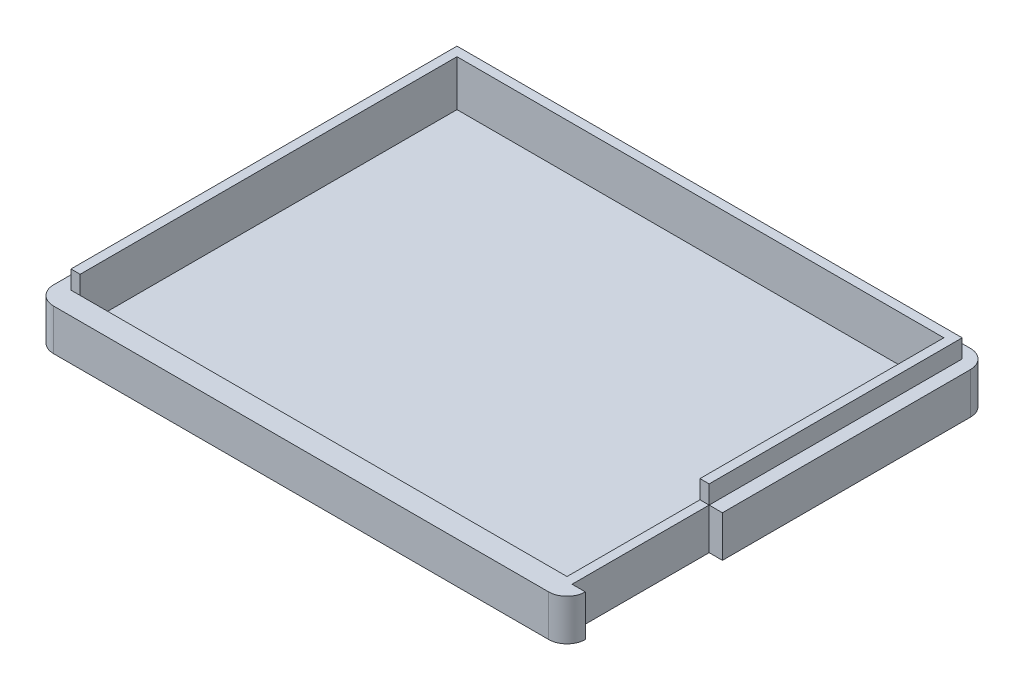
from build123d import *

# Parameters (mm, degrees)
SKETCH1_W           = 58
SKETCH1_H           = 46
BOSS_EXTRUDE1_DEPTH = 4.5
SKETCH2_W           = 55.1
SKETCH2_H           = 43.1
SKETCH2_W_2         = 53.1
SKETCH2_H_2         = 41.1
BOSS_EXTRUDE2_DEPTH = 2
SKETCH3_W           = 53.1
SKETCH3_H           = 41.1
CUT_EXTRUDE1_DEPTH  = 3
SKETCH4_W           = 1
SKETCH4_H           = 15.5
CUT_EXTRUDE2_DEPTH  = 2
CUT_EXTRUDE4_START  = 5
SKETCH5_W           = 54.1
SKETCH5_H           = 1
CUT_EXTRUDE4_DEPTH  = 2
FILLET1_R           = 2
SKETCH6_W           = 1.45
SKETCH6_H           = 14.95
CUT_EXTRUDE5_DEPTH  = 5.5


with BuildPart() as part:
    # Sketch1 → Boss-Extrude1 (new body)
    with BuildSketch(Plane(origin=(0, 0, 0), x_dir=(1, 0, 0), z_dir=(0, 1, 0))):
        with Locations((2.929896907, -5.540206186)):
            Rectangle(SKETCH1_W, SKETCH1_H)
    extrude(amount=BOSS_EXTRUDE1_DEPTH)

    # Sketch2 → Boss-Extrude2 (add)
    with BuildSketch(Plane(origin=(0, 4.5, 0), x_dir=(1, 0, 0), z_dir=(0, 1, 0))):
        with Locations((2.929896907, -5.540206186)):
            Rectangle(SKETCH2_W, SKETCH2_H)
        with Locations((2.929896907, -5.540206186)):
            Rectangle(SKETCH2_W_2, SKETCH2_H_2, mode=Mode.SUBTRACT)
    extrude(amount=BOSS_EXTRUDE2_DEPTH)

    # Sketch3 → Cut-Extrude1 (cut)
    with BuildSketch(Plane(origin=(0, 4.5, 0), x_dir=(1, 0, 0), z_dir=(0, 1, 0))):
        with Locations((2.929896907, -5.540206186)):
            Rectangle(SKETCH3_W, SKETCH3_H)
    extrude(amount=-CUT_EXTRUDE1_DEPTH, mode=Mode.SUBTRACT)

    # Sketch4 → Cut-Extrude2 (cut)
    with BuildSketch(Plane(origin=(0, 6.5, 0), x_dir=(1, 0, 0), z_dir=(0, 1, 0))):
        with Locations((29.979896907, -19.340206186)):
            Rectangle(SKETCH4_W, SKETCH4_H)
    extrude(amount=-CUT_EXTRUDE2_DEPTH, mode=Mode.SUBTRACT)

    # Sketch5 → Cut-Extrude4 (cut)
    with BuildSketch(Plane(origin=(0, 1.5, 0), x_dir=(1, 0, 0), z_dir=(0, 1, 0)).offset(CUT_EXTRUDE4_START)):
        with Locations((2.429896907, -26.590206186)):
            Rectangle(SKETCH5_W, SKETCH5_H)
    extrude(amount=-CUT_EXTRUDE4_DEPTH, mode=Mode.SUBTRACT)

    # Fillet1
    fillet1_edges = [part.edges().sort_by_distance(p)[0] for p in [
        (-26.070103093, 2.25, -17.459793814),
        (31.929896907, 2.25, -17.459793814),
        (31.929896907, 2.25, 28.540206186),
        (-26.070103093, 2.25, 28.540206186),
    ]]
    fillet(fillet1_edges, radius=FILLET1_R)

    # Sketch6 → Cut-Extrude5 (cut, through all)
    with BuildSketch(Plane(origin=(0, 4.5, 0), x_dir=(1, 0, 0), z_dir=(0, 1, 0))):
        with Locations((31.204896907, -19.065206186)):
            Rectangle(SKETCH6_W, SKETCH6_H)
    extrude(amount=-CUT_EXTRUDE5_DEPTH, mode=Mode.SUBTRACT)


solid = part.part
